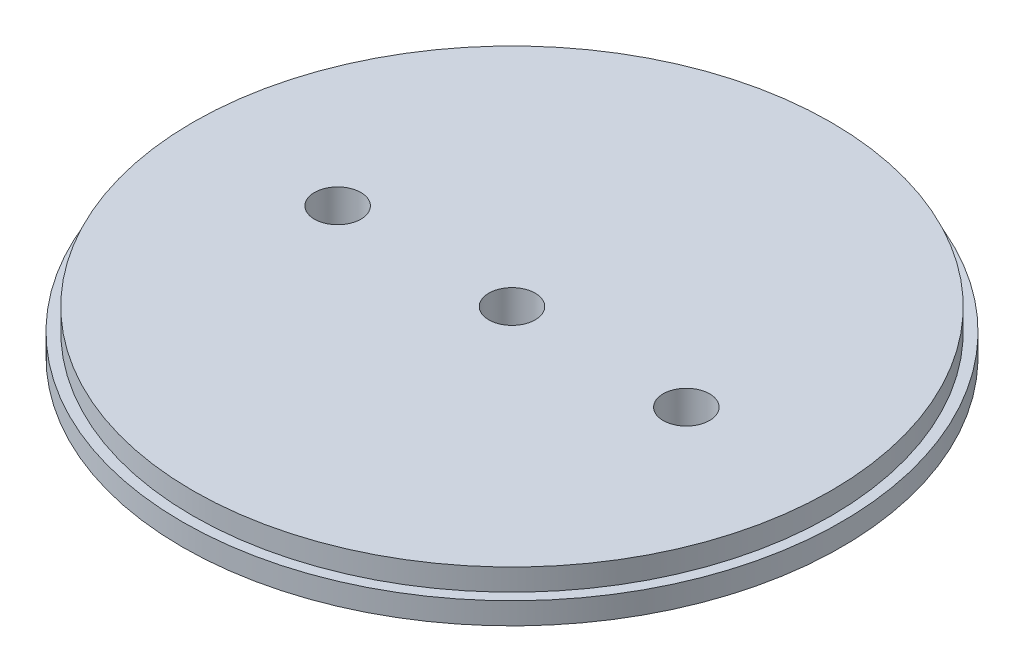
from build123d import *

# Parameters (mm, degrees)
SKETCH1_R                   = 48.006
BOSS_EXTRUDE1_DEPTH         = 3.175
SKETCH2_R                   = 46.482
BOSS_EXTRUDE2_DEPTH         = 3.175
F_1_4_CLEARANCE_HOLE1_D     = 6.7564
F_1_4_CLEARANCE_HOLE1_DEPTH = 48.770172657
F_1_4_CLEARANCE_HOLE1_TIP   = 2.029827343


with BuildPart() as part:
    # Sketch1 → Boss-Extrude1 (new body)
    with BuildSketch(Plane(origin=(0, 0, 0), x_dir=(1, 0, 0), z_dir=(0, 1, 0))):
        Circle(SKETCH1_R)
    extrude(amount=BOSS_EXTRUDE1_DEPTH)

    # Sketch2 → Boss-Extrude2 (add)
    with BuildSketch(Plane(origin=(0, 3.175, 0), x_dir=(1, 0, 0), z_dir=(0, 1, 0))):
        Circle(SKETCH2_R)
    extrude(amount=BOSS_EXTRUDE2_DEPTH)

    # 1/4 Clearance Hole1
    with Locations(Plane(origin=(0, 0, 0), x_dir=(-1, 0, 0), z_dir=(0, -1, 0))):
        with Locations((-25.4, 0), (0, 0), (25.4, 0)):
            Hole(F_1_4_CLEARANCE_HOLE1_D / 2, depth=F_1_4_CLEARANCE_HOLE1_DEPTH)
            with Locations((0, 0, -(F_1_4_CLEARANCE_HOLE1_DEPTH + F_1_4_CLEARANCE_HOLE1_TIP / 2))):  # 118° drill point
                Cone(0, F_1_4_CLEARANCE_HOLE1_D / 2, F_1_4_CLEARANCE_HOLE1_TIP, mode=Mode.SUBTRACT)


solid = part.part
